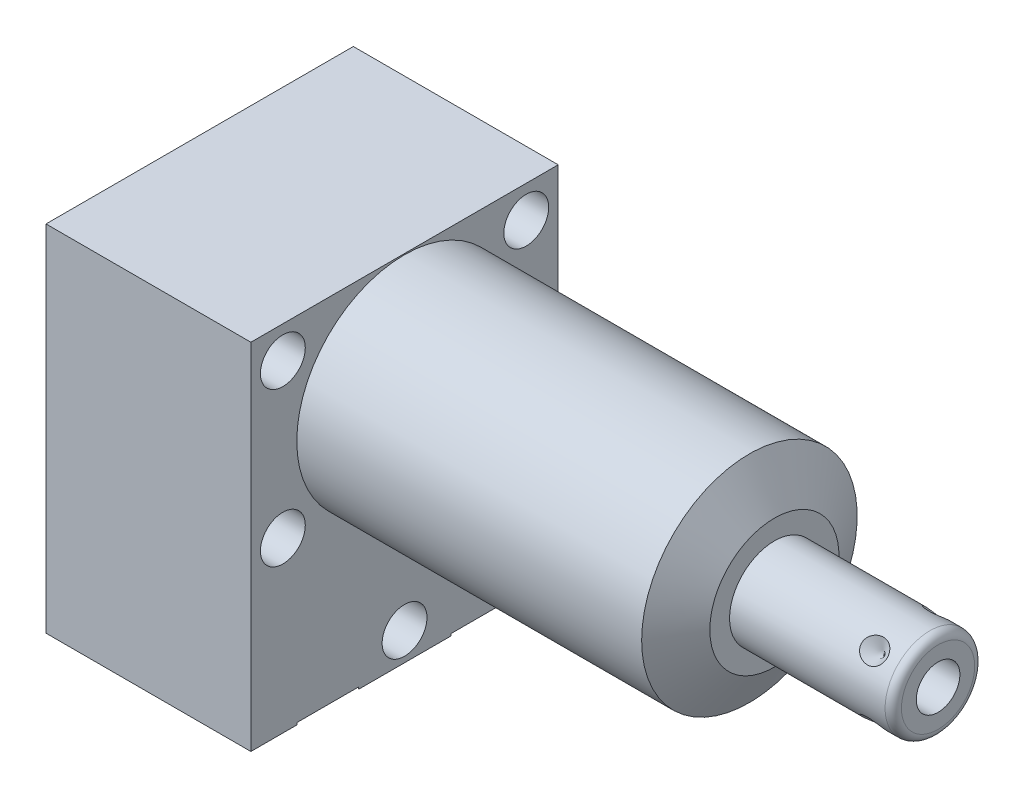
from build123d import *

# Parameters (mm, degrees)
SKETCH1_W           = 38.1
SKETCH1_H           = 43.942
EXTRUDE1_DEPTH      = 45.847
EXTRUDE1_DEPTH_BACK = 25.4
CUT_EXTRUDE1_REACH  = 47.847
SKETCH2_W           = 38.1
SKETCH2_H           = 43.942
SKETCH2_R           = 13.3604
SKETCH14_R          = 7.9375
CUT_EXTRUDE2_DEPTH  = 2.667
SKETCH10_R          = 6.4389
EXTRUDE2_DEPTH      = 1.651
SKETCH11_R          = 4.8006
EXTRUDE3_DEPTH      = 2.667
CIRPATTERN1_COUNT   = 4
HOLE1_D             = 5.5626
HOLE1_DEPTH         = 25.4


with BuildPart() as part:
    # Sketch1 → Extrude1 (new body, two sides)
    with BuildSketch(Plane(origin=(0, 0, 0), x_dir=(0, 0, -1), z_dir=(1, 0, 0))) as extrude1_sk:
        with Locations((0, -8.4836)):
            Rectangle(SKETCH1_W, SKETCH1_H)
    extrude(amount=EXTRUDE1_DEPTH)
    extrude(extrude1_sk.sketch, amount=-EXTRUDE1_DEPTH_BACK)

    # Sketch2 → Cut-Extrude1 (cut, up to next)
    with BuildSketch(Plane(origin=(0, 0, 0), x_dir=(0, 0, -1), z_dir=(1, 0, 0)), mode=Mode.PRIVATE) as cut_extrude1_sk1:
        with Locations((0, -8.4836)):
            Rectangle(SKETCH2_W, SKETCH2_H)
        Circle(SKETCH2_R, mode=Mode.SUBTRACT)
    cut_extrude1_tool1 = extrude(cut_extrude1_sk1.sketch, amount=CUT_EXTRUDE1_REACH, mode=Mode.PRIVATE) & part.part
    add(cut_extrude1_tool1.solids().sort_by_distance((0, 13.429241, 0))[0], mode=Mode.SUBTRACT)

    # Sketch3 → Cut-Revolve1 (revolve, cut)
    with BuildSketch(Plane.XY, mode=Mode.PRIVATE) as cut_revolve1_sk:
        Polygon((42.752748967, 13.3604), (45.847, 8.001), (45.847, 13.3604), align=None)
    revolve(cut_revolve1_sk.sketch.rotate(Axis((42.598036416, 0, 0), (1, 0, 0)), 90), axis=Axis((42.598036416, 0, 0), (1, 0, 0)), mode=Mode.SUBTRACT)  # turned: the seam where the file's is

    # S2D0002 → Cut-Revolve2 (revolve, cut)
    with BuildSketch(Plane(origin=(-22.733, -19.8374, 9.525), x_dir=(0, 1, 0), z_dir=(0, 0, 1)), mode=Mode.PRIVATE) as cut_revolve2_sk:
        Polygon((-0.8128, 0), (3.7338, 0), (3.293786662, -2.0701), (2.6416, -2.722286662), (2.6416, -13.97), (-0.8128, -13.97), align=None)
    revolve(cut_revolve2_sk.sketch.rotate(Axis((-8.0645, -20.6502, 9.525), (-1, 0, 0)), 90), axis=Axis((-8.0645, -20.6502, 9.525), (-1, 0, 0)), mode=Mode.SUBTRACT)  # turned: the seam where the file's is

    # Sketch5 → Cut-Revolve3 (revolve, cut)
    with BuildSketch(Plane(origin=(-22.733, -19.8374, -9.525), x_dir=(0, 1, 0), z_dir=(0, 0, 1)), mode=Mode.PRIVATE) as cut_revolve3_sk:
        Polygon((-0.8128, 0), (3.7338, 0), (3.293786662, -2.0701), (2.6416, -2.722286662), (2.6416, -13.97), (-0.8128, -13.97), align=None)
    revolve(cut_revolve3_sk.sketch.rotate(Axis((-8.0645, -20.6502, -9.525), (-1, 0, 0)), 90), axis=Axis((-8.0645, -20.6502, -9.525), (-1, 0, 0)), mode=Mode.SUBTRACT)  # turned: the seam where the file's is

    # Sketch14 → Cut-Extrude2 (cut)
    with BuildSketch(Plane.ZY.offset(25.4)):
        with Locations((-9.525, -20.6502)):
            Circle(SKETCH14_R)
        with Locations((9.525, -20.6502)):
            Circle(SKETCH14_R)
    extrude(amount=-CUT_EXTRUDE2_DEPTH, mode=Mode.SUBTRACT)

    # Sketch6 → Cut-Revolve4 (revolve, cut)
    with BuildSketch(Plane(origin=(-8.7376, -30.2006, 9.525), x_dir=(-1, 0, 0), z_dir=(0, 0, 1)), mode=Mode.PRIVATE) as cut_revolve4_sk:
        Polygon((6.18363, 0), (5.641036865, -2.5527), (4.97713, -3.216606865), (4.97713, -17.272), (0, -17.272), (0, 0), (0, 0.254), (9.52373, 0.254), (9.52373, 0), align=None)
    revolve(cut_revolve4_sk.sketch.rotate(Axis((-8.7376, -12.065, 9.525), (0, -1, 0)), 270), axis=Axis((-8.7376, -12.065, 9.525), (0, -1, 0)), mode=Mode.SUBTRACT)  # turned: the seam where the file's is

    # Sketch7 → Cut-Revolve5 (revolve, cut)
    with BuildSketch(Plane(origin=(-8.7376, -30.2006, -9.525), x_dir=(-1, 0, 0), z_dir=(0, 0, 1)), mode=Mode.PRIVATE) as cut_revolve5_sk:
        Polygon((6.1849, 0), (5.642306865, -2.5527), (4.9784, -3.216606865), (4.9784, -17.272), (0, -17.272), (0, 0), (0, 0.254), (9.52373, 0.254), (9.52373, 0), align=None)
    revolve(cut_revolve5_sk.sketch.rotate(Axis((-8.7376, -12.065, -9.525), (0, -1, 0)), 270), axis=Axis((-8.7376, -12.065, -9.525), (0, -1, 0)), mode=Mode.SUBTRACT)  # turned: the seam where the file's is

    # Sketch8 → Revolve1 (revolve)
    with BuildSketch(Plane.XY, mode=Mode.PRIVATE) as revolve1_sk:
        with BuildLine():
            Line((45.847, 0), (45.847, 5.55625))
            Line((45.847, 5.55625), (65.1256, 5.55625))
            ThreePointArc((65.1256, 5.55625), (65.84402049, 5.25867049), (66.1416, 4.54025))
            Line((66.1416, 4.54025), (66.1416, 0))
            Line((66.1416, 0), (45.847, 0))
        make_face()
    revolve(revolve1_sk.sketch.rotate(Axis((44.83227, 0, 0), (1, 0, 0)), 90), axis=Axis((44.83227, 0, 0), (1, 0, 0)))  # turned: the seam where the file's is

    # S2D0001 → Cut-Revolve6 (revolve, cut)
    with BuildSketch(Plane(origin=(66.1416, -2.8067, 0), x_dir=(0, -1, 0), z_dir=(0, 0, 1)), mode=Mode.PRIVATE) as cut_revolve6_sk:
        Polygon((-0.1016, 0), (-0.1016, -9.652), (-2.8067, -11.277388061), (-2.8067, 0), align=None)
    revolve(cut_revolve6_sk.sketch.rotate(Axis((53.702842726, 0, 0), (1, 0, 0)), 270), axis=Axis((53.702842726, 0, 0), (1, 0, 0)), mode=Mode.SUBTRACT)  # turned: the seam where the file's is

    # Sketch10 → Extrude2 (add)
    with BuildSketch(Plane(origin=(-25.4, -30.2006, 0), x_dir=(0, 0, -1), z_dir=(0, -1, 0))):
        with Locations(Location((-9.525, 16.6624, 0), (0, 0, 180))):  # turned: the seam where the file's is
            Circle(SKETCH10_R)
    extrude(amount=EXTRUDE2_DEPTH)

    # Sketch11 → Extrude3 (add)
    with BuildSketch(Plane.ZY.offset(22.733)):
        with Locations(Location((9.525, -20.6502, 0), (0, 0, 180))):  # turned: the seam where the file's is
            Circle(SKETCH11_R)
    extrude(amount=EXTRUDE3_DEPTH)

    # Sketch12 → Cut-Revolve7 (revolve, cut)
    with BuildSketch(Plane(origin=(62.1792, 3.928862053, -3.928862053), x_dir=(-1, 0, 0), z_dir=(0, -0.707106781, -0.707106781)), mode=Mode.PRIVATE) as cut_revolve7_sk:
        Polygon((0, 0), (1.5875, 0), (0, -1.5875), align=None)
    cut_revolve7 = revolve(cut_revolve7_sk.sketch.rotate(Axis((62.1792, 1.500688387, -1.500688387), (0, 0.707106781, -0.707106781)), 90), axis=Axis((62.1792, 1.500688387, -1.500688387), (0, 0.707106781, -0.707106781)), mode=Mode.SUBTRACT)  # turned: the seam where the file's is

    # CirPattern1: Cut-Revolve7 ×4 about axis
    cirpattern1_axis = Axis((45.848, 0, 0), (-1, 0, 0))
    for i in range(1, CIRPATTERN1_COUNT):
        add(cut_revolve7.rotate(cirpattern1_axis, i * 360 / CIRPATTERN1_COUNT), mode=Mode.SUBTRACT)

    # Hole1
    with Locations(Plane(origin=(0, 0, 0), x_dir=(0, 0, -1), z_dir=(1, 0, 0))):
        with Locations((-15.0876, 9.525), (-15.0876, -9.525), (15.0876, 9.525), (15.0876, -9.525), (0, -26.9748)):
            Hole(HOLE1_D / 2, depth=HOLE1_DEPTH)


solid = part.part
